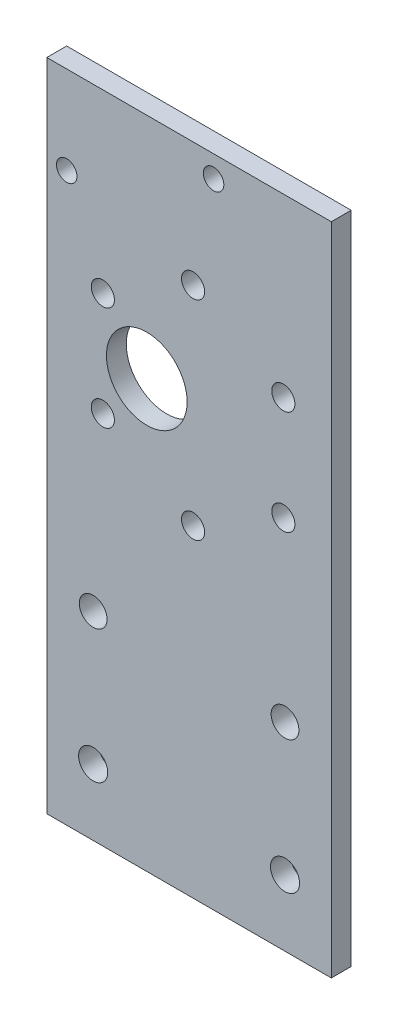
from build123d import *

# Parameters (mm, degrees)
SKETCH_1_W          = 40
SKETCH_1_H          = 29
EXTRUDE_1_DEPTH     = 3
CUT_EXTRUDE_1_DEPTH = 3
SKETCH_3_W          = 40
SKETCH_3_H          = 3
EXTRUDE_2_DEPTH     = 10
SKETCH_4_W          = 40
SKETCH_4_H          = 3
EXTRUDE_3_DEPTH     = 10
SKETCH_6_W          = 3
SKETCH_6_H          = 49
EXTRUDE_5_DEPTH     = 42
SKETCH_8_W          = 3
SKETCH_8_H          = 49
EXTRUDE_6_DEPTH     = 2
SKETCH_9_W          = 3
SKETCH_9_H          = 49
EXTRUDE_7_DEPTH     = 2
SKETCH_10_W         = 86
SKETCH_10_H         = 3
EXTRUDE_8_DEPTH     = 10
SKETCH_11_W         = 86
SKETCH_11_H         = 3
EXTRUDE_9_DEPTH     = 10
SKETCH_7_R          = 1.75
SKETCH_7_R_2        = 6.1
CUT_EXTRUDE_4_DEPTH = 10
SKETCH_14_W         = 3
SKETCH_14_H         = 69
CUT_EXTRUDE_5_DEPTH = 43
SKETCH_17_W         = 43
SKETCH_17_H         = 3
EXTRUDE_10_DEPTH    = 20
SKETCH_18_R         = 2.1
CUT_EXTRUDE_6_DEPTH = 10
SKETCH_20_W         = 43
SKETCH_20_H         = 3
EXTRUDE_11_DEPTH    = 10
SKETCH_21_W         = 43
SKETCH_21_H         = 3
CUT_EXTRUDE_7_DEPTH = 10
SKETCH_22_R         = 2.2
CUT_EXTRUDE_8_DEPTH = 10
SKETCH_24_W         = 43
SKETCH_24_H         = 3
EXTRUDE_12_DEPTH    = 10
SKETCH_25_R         = 1.55
CUT_EXTRUDE_9_DEPTH = 10


with BuildPart() as part:
    # ｽｹｯﾁ1 → ﾎﾞｽ - 押し出し1 (new body)
    with BuildSketch(Plane.XY):
        Rectangle(SKETCH_1_W, SKETCH_1_H)
    extrude(amount=EXTRUDE_1_DEPTH)

    # ｽｹｯﾁ2 → ｶｯﾄ - 押し出し1 (cut)
    with BuildSketch(Plane.XY.offset(3)):
        with BuildLine():
            ThreePointArc((-14.4, 10.5), (-15.01507576, 11.98492424), (-16.5, 12.6))
            Line((-16.5, 12.6), (-16.5, 10.5))
            Line((-16.5, 10.5), (-18.6, 10.5))
            ThreePointArc((-18.6, 10.5), (-16.5, 8.4), (-14.4, 10.5))
        make_face()
        with BuildLine():
            Line((-16.5, 10.5), (-16.5, 12.6))
            ThreePointArc((-16.5, 12.6), (-17.98492424, 11.98492424), (-18.6, 10.5))
            Line((-18.6, 10.5), (-16.5, 10.5))
        make_face()
        with BuildLine():
            ThreePointArc((-18.6, -10.5), (-17.98492424, -11.98492424), (-16.5, -12.6))
            Line((-16.5, -12.6), (-16.5, -10.5))
            Line((-16.5, -10.5), (-18.6, -10.5))
        make_face()
        with BuildLine():
            Line((-16.5, -10.5), (-16.5, -12.6))
            ThreePointArc((-16.5, -12.6), (-15.01507576, -11.98492424), (-14.4, -10.5))
            ThreePointArc((-14.4, -10.5), (-16.5, -8.4), (-18.6, -10.5))
            Line((-18.6, -10.5), (-16.5, -10.5))
        make_face()
        with BuildLine():
            ThreePointArc((18.6, -10.5), (15.01507576, -9.01507576), (16.5, -12.6))
            Line((16.5, -12.6), (16.5, -10.5))
            Line((16.5, -10.5), (18.6, -10.5))
        make_face()
        with BuildLine():
            Line((16.5, -10.5), (16.5, -12.6))
            ThreePointArc((16.5, -12.6), (17.98492424, -11.98492424), (18.6, -10.5))
            Line((18.6, -10.5), (16.5, -10.5))
        make_face()
        with BuildLine():
            ThreePointArc((18.6, 10.5), (17.98492424, 11.98492424), (16.5, 12.6))
            Line((16.5, 12.6), (16.5, 10.5))
            Line((16.5, 10.5), (18.6, 10.5))
        make_face()
        with BuildLine():
            Line((16.5, 10.5), (16.5, 12.6))
            ThreePointArc((16.5, 12.6), (15.01507576, 9.01507576), (18.6, 10.5))
            Line((18.6, 10.5), (16.5, 10.5))
        make_face()
    extrude(amount=-CUT_EXTRUDE_1_DEPTH, mode=Mode.SUBTRACT)

    # ｽｹｯﾁ3 → ﾎﾞｽ - 押し出し2 (add)
    with BuildSketch(Plane.XZ.offset(14.5)):
        with Locations((0, 1.5)):
            Rectangle(SKETCH_3_W, SKETCH_3_H)
    extrude(amount=EXTRUDE_2_DEPTH)

    # ｽｹｯﾁ4 → ﾎﾞｽ - 押し出し3 (add)
    with BuildSketch(Plane(origin=(0, 14.5, 0), x_dir=(1, 0, 0), z_dir=(0, 1, 0))):
        with Locations((0, -1.5)):
            Rectangle(SKETCH_4_W, SKETCH_4_H)
    extrude(amount=EXTRUDE_3_DEPTH)

    # ｽｹｯﾁ6 → ﾎﾞｽ - 押し出し5 (add)
    with BuildSketch(Plane(origin=(20, 0, 0), x_dir=(0, 0, -1), z_dir=(1, 0, 0))):
        with Locations((-1.5, 0)):
            Rectangle(SKETCH_6_W, SKETCH_6_H)
    extrude(amount=EXTRUDE_5_DEPTH)

    # ｽｹｯﾁ8 → ﾎﾞｽ - 押し出し6 (add)
    with BuildSketch(Plane.ZY.offset(20)):
        with Locations((1.5, 0)):
            Rectangle(SKETCH_8_W, SKETCH_8_H)
    extrude(amount=EXTRUDE_6_DEPTH)

    # ｽｹｯﾁ9 → ﾎﾞｽ - 押し出し7 (add)
    with BuildSketch(Plane(origin=(62, 0, 0), x_dir=(0, 0, -1), z_dir=(1, 0, 0))):
        with Locations((-1.5, 0)):
            Rectangle(SKETCH_9_W, SKETCH_9_H)
    extrude(amount=EXTRUDE_7_DEPTH)

    # ｽｹｯﾁ10 → ﾎﾞｽ - 押し出し8 (add)
    with BuildSketch(Plane.XZ.offset(24.5)):
        with Locations((21, 1.5)):
            Rectangle(SKETCH_10_W, SKETCH_10_H)
    extrude(amount=EXTRUDE_8_DEPTH)

    # ｽｹｯﾁ11 → ﾎﾞｽ - 押し出し9 (add)
    with BuildSketch(Plane(origin=(0, 24.5, 0), x_dir=(1, 0, 0), z_dir=(0, 1, 0))):
        with Locations((21, -1.5)):
            Rectangle(SKETCH_11_W, SKETCH_11_H)
    extrude(amount=EXTRUDE_9_DEPTH)

    # ｽｹｯﾁ7 → ｶｯﾄ - 押し出し4 (cut)
    with BuildSketch(Plane.XY.offset(3)):
        with Locations((56.745697969, 7.875)):
            Circle(SKETCH_7_R)
        with Locations((56.745697969, -7.875)):
            Circle(SKETCH_7_R)
        with Locations((36.10579786, 0)):
            Circle(SKETCH_7_R_2)
        with Locations((43.10579786, 15.75)):
            Circle(SKETCH_7_R)
        with Locations((43.10579786, -15.75)):
            Circle(SKETCH_7_R)
        with Locations((29.46589775, 7.875)):
            Circle(SKETCH_7_R)
        with Locations((29.46589775, -7.875)):
            Circle(SKETCH_7_R)
    extrude(amount=-CUT_EXTRUDE_4_DEPTH, mode=Mode.SUBTRACT)

    # ｽｹｯﾁ14 → ｶｯﾄ - 押し出し5 (cut)
    with BuildSketch(Plane.ZY.offset(22)):
        with Locations((1.5, 0)):
            Rectangle(SKETCH_14_W, SKETCH_14_H)
    extrude(amount=-CUT_EXTRUDE_5_DEPTH, mode=Mode.SUBTRACT)

    # ｽｹｯﾁ17 → ﾎﾞｽ - 押し出し10 (add)
    with BuildSketch(Plane.XZ.offset(34.5)):
        with Locations((42.5, 1.5)):
            Rectangle(SKETCH_17_W, SKETCH_17_H)
    extrude(amount=EXTRUDE_10_DEPTH)

    # ｽｹｯﾁ18 → ｶｯﾄ - 押し出し6 (cut)
    with BuildSketch(Plane.XY.offset(3)):
        with Locations((28, -34.5)):
            Circle(SKETCH_18_R)
        with Locations((57, -34.5)):
            Circle(SKETCH_18_R)
    extrude(amount=-CUT_EXTRUDE_6_DEPTH, mode=Mode.SUBTRACT)

    # ｽｹｯﾁ20 → ﾎﾞｽ - 押し出し11 (add)
    with BuildSketch(Plane.XZ.offset(54.5)):
        with Locations((42.5, 1.5)):
            Rectangle(SKETCH_20_W, SKETCH_20_H)
    extrude(amount=EXTRUDE_11_DEPTH)

    # ｽｹｯﾁ21 → ｶｯﾄ - 押し出し7 (cut)
    with BuildSketch(Plane(origin=(0, 34.5, 0), x_dir=(1, 0, 0), z_dir=(0, 1, 0))):
        with Locations((42.5, -1.5)):
            Rectangle(SKETCH_21_W, SKETCH_21_H)
    extrude(amount=-CUT_EXTRUDE_7_DEPTH, mode=Mode.SUBTRACT)

    # ｽｹｯﾁ22 → ｶｯﾄ - 押し出し8 (cut)
    with BuildSketch(Plane.XY.offset(3)):
        with Locations((28, -54.5)):
            Circle(SKETCH_22_R)
        with Locations((57, -54.5)):
            Circle(SKETCH_22_R)
    extrude(amount=-CUT_EXTRUDE_8_DEPTH, mode=Mode.SUBTRACT)

    # ｽｹｯﾁ24 → ﾎﾞｽ - 押し出し12 (add)
    with BuildSketch(Plane(origin=(0, 24.5, 0), x_dir=(1, 0, 0), z_dir=(0, 1, 0))):
        with Locations((42.5, -1.5)):
            Rectangle(SKETCH_24_W, SKETCH_24_H)
    extrude(amount=EXTRUDE_12_DEPTH)

    # ｽｹｯﾁ25 → ｶｯﾄ - 押し出し9 (cut)
    with BuildSketch(Plane.XY.offset(3)):
        with Locations((24, 21.2)):
            Circle(SKETCH_25_R)
        with Locations((46.2, 31.2)):
            Circle(SKETCH_25_R)
    extrude(amount=-CUT_EXTRUDE_9_DEPTH, mode=Mode.SUBTRACT)


solid = part.part
